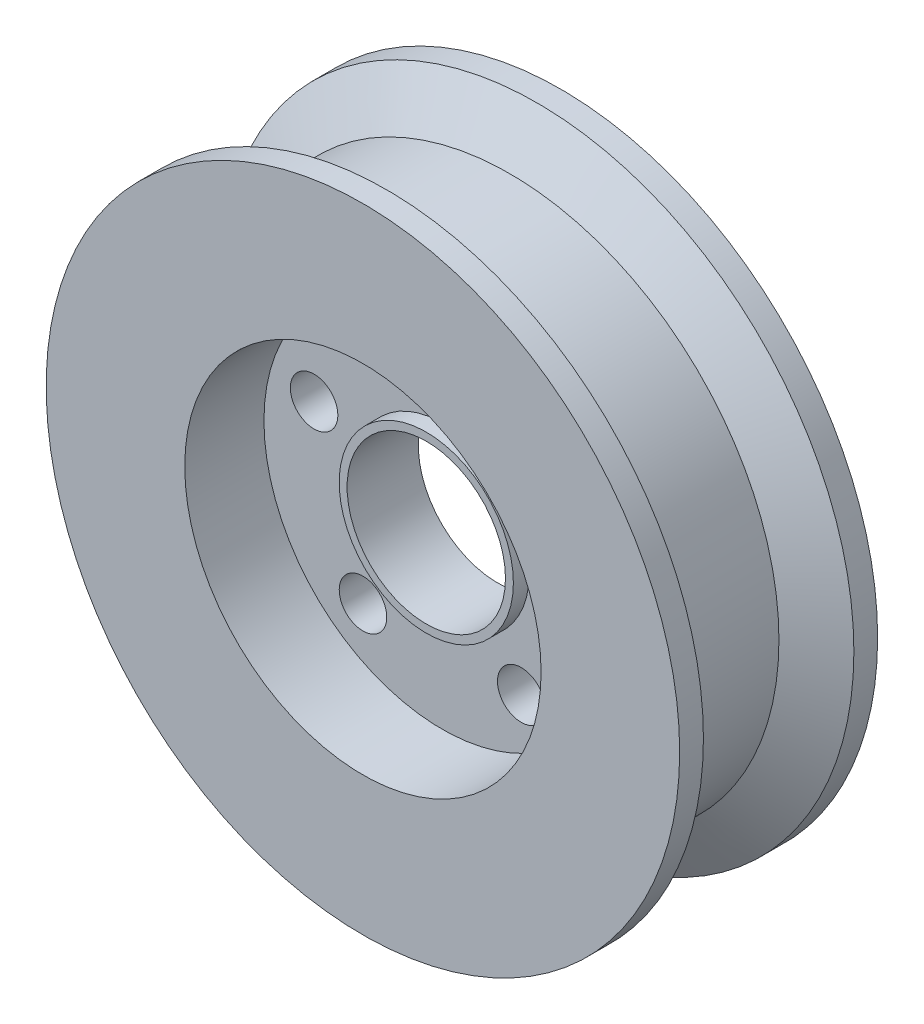
from build123d import *

# Parameters (mm, degrees)
SKETCH1_R                = 40
SKETCH1_R_2              = 10
BOSS_EXTRUDE1_DEPTH      = 12.5
SKETCH2_R                = 22.5
CUT_EXTRUDE1_DEPTH       = 10
SKETCH3_R                = 3
CUT_EXTRUDE2_DEPTH       = 16
CIRPATTERN1_COUNT        = 5
SKETCH4_R                = 11
SKETCH4_R_2              = 10
BOSS_EXTRUDE2_DEPTH      = 2
BOSS_EXTRUDE2_DEPTH_BACK = 7


with BuildPart() as part:
    # Sketch1 → Boss-Extrude1 (new body, symmetric)
    with BuildSketch(Plane.XY):
        Circle(SKETCH1_R)
        Circle(SKETCH1_R_2, mode=Mode.SUBTRACT)
    extrude(amount=BOSS_EXTRUDE1_DEPTH, both=True)

    # Sketch2 → Cut-Extrude1 (cut)
    with BuildSketch(Plane.XY.offset(12.5)):
        Circle(SKETCH2_R)
    cut_extrude1 = extrude(amount=-CUT_EXTRUDE1_DEPTH, mode=Mode.SUBTRACT)

    # Mirror1: Cut-Extrude1 across plane
    add(cut_extrude1.mirror(Plane.XY), mode=Mode.SUBTRACT)

    # Sketch3 → Cut-Extrude2 (cut, through all)
    with BuildSketch(Plane.XY.offset(2.5)):
        with Locations((0, 17)):
            Circle(SKETCH3_R)
    cut_extrude2 = extrude(amount=-CUT_EXTRUDE2_DEPTH, mode=Mode.SUBTRACT)

    # CirPattern1: Cut-Extrude2 ×5 about axis
    cirpattern1_axis = Axis((0, 0, 0), (0, 0, 1))
    for i in range(1, CIRPATTERN1_COUNT):
        add(cut_extrude2.rotate(cirpattern1_axis, i * 360 / CIRPATTERN1_COUNT), mode=Mode.SUBTRACT)

    # Sketch4 → Boss-Extrude2 (add, two sides)
    with BuildSketch(Plane.XY.offset(2.5)) as boss_extrude2_sk:
        Circle(SKETCH4_R)
        Circle(SKETCH4_R_2, mode=Mode.SUBTRACT)
    extrude(amount=BOSS_EXTRUDE2_DEPTH)
    extrude(boss_extrude2_sk.sketch, amount=-BOSS_EXTRUDE2_DEPTH_BACK)

    # Sketch5 → Cut-Revolve1 (revolve, cut)
    with BuildSketch(Plane(origin=(0, 0, 0), x_dir=(1, 0, 0), z_dir=(0, 1, 0))):
        Polygon((-40, 9.5), (-34, 6.035898385), (-34, -6.035898385), (-40, -9.5), align=None)
    revolve(axis=Axis((0, 0, 0), (0, 0, -1)), mode=Mode.SUBTRACT)


solid = part.part
